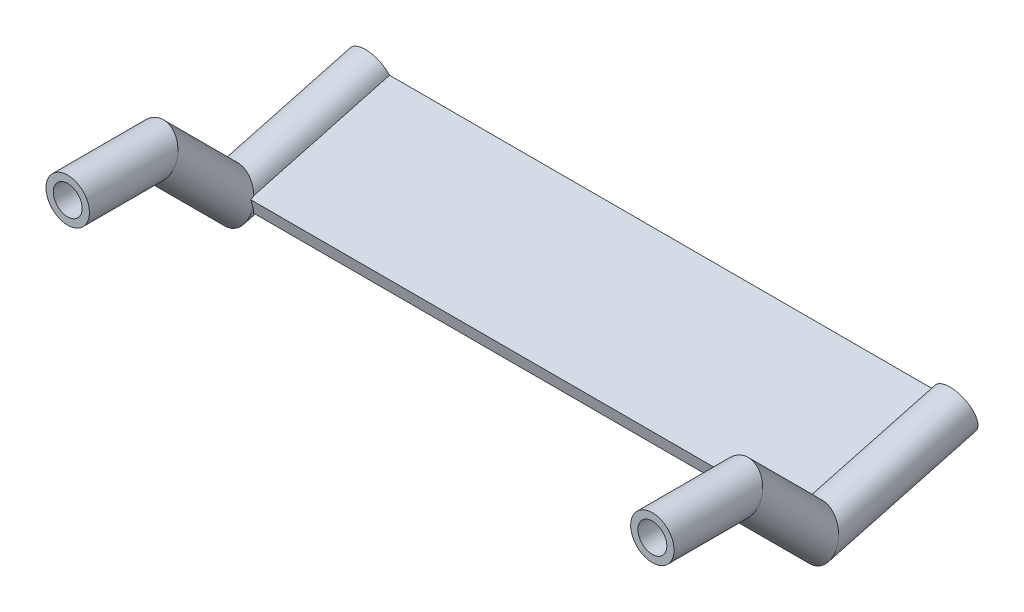
from build123d import *

# Parameters (mm, degrees)
SWEEP_THIN1_PROFILE_R   = 30
SWEEP_THIN1_PROFILE_R_2 = 20
EXTRUDE_THIN1_START     = 20
EXTRUDE_THIN1_DEPTH     = 760


with BuildPart() as part:
    # Sweep-Thin1: sweep along a path in Sketch21
    with BuildLine(Plane(origin=(0, 0, 0), x_dir=(0, 0, -1), z_dir=(1, 0, 0))) as sweep_thin1_path:
        Line((0, 0), (120, 0))
        Line((120, 0), (226.066017178, -106.066017178))
        Line((226.066017178, -106.066017178), (419.251182436, -54.302208157))
    # Sweep-Thin1 profile (on start of the path) → Sweep-Thin1 (sweep)
    with BuildSketch(Plane(origin=(0, 0, 0), x_dir=(-1, 0, 0), z_dir=(0, 0, -1))):
        Circle(SWEEP_THIN1_PROFILE_R)
        Circle(SWEEP_THIN1_PROFILE_R_2, mode=Mode.SUBTRACT)
    sweep_thin1 = sweep(path=sweep_thin1_path.line, transition=Transition.RIGHT)

    # Sketch32 → Extrude-Thin1 (add)
    with BuildSketch(Plane(origin=(0, 0, 0), x_dir=(0, 0, -1), z_dir=(1, 0, 0)).offset(EXTRUDE_THIN1_START)):
        Polygon((228.654207629, -115.725275441), (421.839372887, -63.96146642), (416.662991985, -44.642949895), (223.477826727, -96.406758915), align=None)
    extrude(amount=EXTRUDE_THIN1_DEPTH)

    # Mirror1: Sweep-Thin1 across plane
    add(sweep_thin1.mirror(Plane(origin=(404.142135624, 0, 0), x_dir=(0, 0, 1), z_dir=(1, 0, 0))))


solid = part.part
